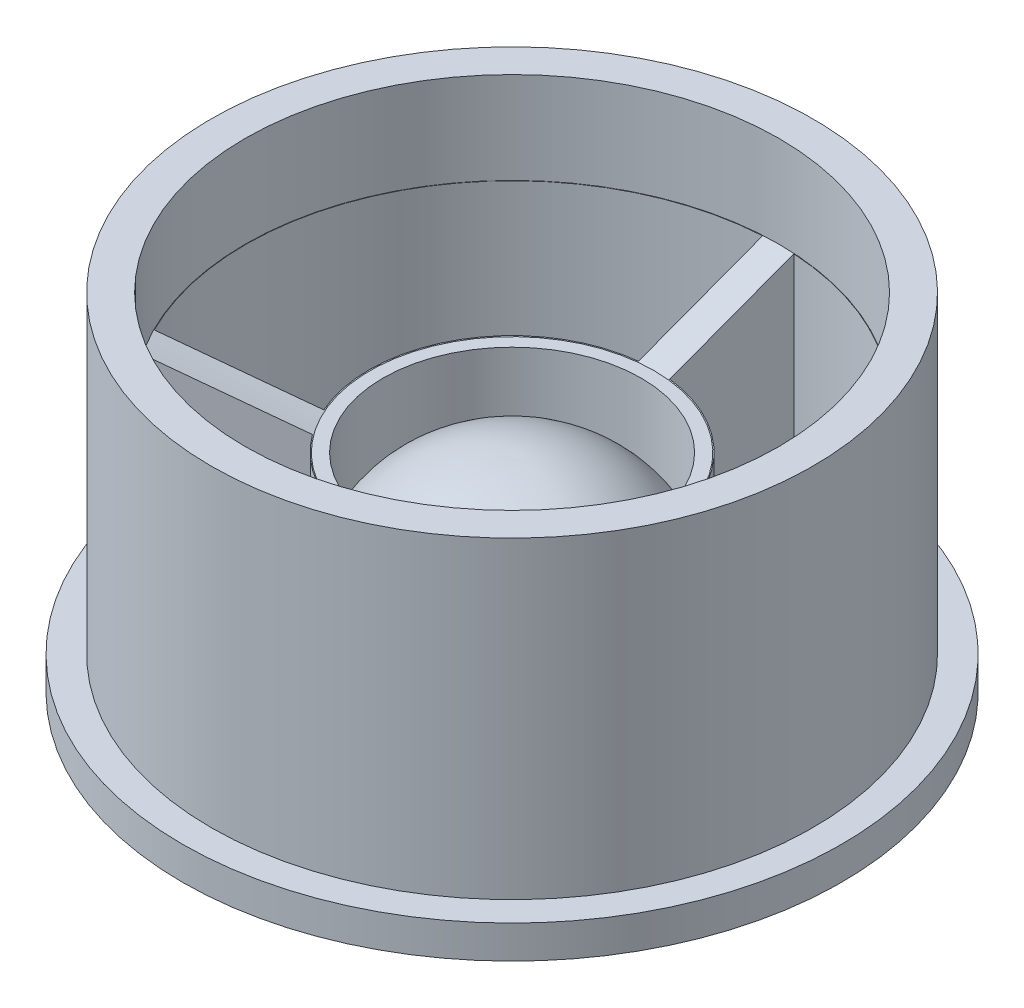
from build123d import *

# Parameters (mm, degrees)
SKETCH_1_R          = 10
SKETCH_1_R_2        = 9.128348481
EXTRUDE_2_DEPTH     = 1
SKETCH_1_4_R        = 9.128348481
EXTRUDE_4_DEPTH     = 10.5
SKETCH_1_5_R        = 1.1
CUT_EXTRUDE_1_DEPTH = 5


with BuildPart() as part:
    # 草图1 → 凸台-拉伸2 (new body)
    with BuildSketch(Plane(origin=(0, 0, 0), x_dir=(1, 0, 0), z_dir=(0, 1, 0))):
        Circle(SKETCH_1_R)
        Circle(SKETCH_1_R_2, mode=Mode.SUBTRACT)
    extrude(amount=EXTRUDE_2_DEPTH)

    # 草图1<4> → 凸台-拉伸4 (add)
    with BuildSketch(Plane(origin=(0, 0, 0), x_dir=(1, 0, 0), z_dir=(0, 1, 0))):
        Circle(SKETCH_1_4_R)
        with BuildLine():
            Line((0.473140602, 4.307795347), (0.473140602, 8.075783591))
            ThreePointArc((0.473140602, 8.075783591), (7.005826645, 4.044815899), (7.230404046, -3.628140015))
            Line((7.230404046, -3.628140015), (3.967230505, -1.744145892))
            ThreePointArc((3.967230505, -1.744145892), (3.753095001, 2.166850409), (0.473140602, 4.307795347))
        make_face(mode=Mode.SUBTRACT)
        with BuildLine():
            Line((-0.473140602, 8.075783591), (-0.473140602, 4.307795347))
            ThreePointArc((-0.473140602, 4.307795347), (-3.753095001, 2.166850409), (-3.967230505, -1.744145892))
            Line((-3.967230505, -1.744145892), (-7.230404046, -3.628140015))
            ThreePointArc((-7.230404046, -3.628140015), (-7.005826645, 4.044815899), (-0.473140602, 8.075783591))
        make_face(mode=Mode.SUBTRACT)
        with BuildLine():
            ThreePointArc((-3.494089903, -2.563649454), (0, -4.333700818), (3.494089903, -2.563649454))
            Line((3.494089903, -2.563649454), (6.757263444, -4.447643576))
            ThreePointArc((6.757263444, -4.447643576), (0, -8.089631799), (-6.757263444, -4.447643576))
            Line((-6.757263444, -4.447643576), (-3.494089903, -2.563649454))
        make_face(mode=Mode.SUBTRACT)
    extrude(amount=EXTRUDE_4_DEPTH)

    # 草图2 → 切除-旋转1 (revolve, cut)
    with BuildSketch(Plane(origin=(0, 0, 0), x_dir=(0, 0, -1), z_dir=(1, 0, 0))):
        with BuildLine():
            Line((8.099016848, 10.5), (8.099016848, 7.718955254))
            Line((8.099016848, 7.718955254), (4.307795347, 6.293437734))
            Line((4.307795347, 6.293437734), (3.916728598, 6.293437734))
            Line((3.916728598, 6.293437734), (3.916728598, 3.964130755))
            add(Edge.make_bspline(
                [(3.916728598, 3.964130755), (3.198487501, 5.366870317), (1.55626671, 6.233016223), (0, 6.17174819)],
                knots=[0, 0, 0, 0, 1, 1, 1, 1], degree=3))
            Line((0, 6.17174819), (0, 6.293437734))
            Line((0, 6.293437734), (0, 10.5))
            Line((0, 10.5), (8.099016848, 10.5))
        make_face()
    revolve(axis=Axis((0, 2.702728724, 0), (0, 1, 0)), mode=Mode.SUBTRACT)

    # 草图1<5> → 切除-拉伸1 (cut)
    with BuildSketch(Plane(origin=(0, 0, 0), x_dir=(1, 0, 0), z_dir=(0, 1, 0))):
        Circle(SKETCH_1_5_R)
    extrude(amount=CUT_EXTRUDE_1_DEPTH, mode=Mode.SUBTRACT)

    # 草图3 → 旋转1 (revolve)
    with BuildSketch(Plane(origin=(0, 0, 0), x_dir=(0, 0, -1), z_dir=(1, 0, 0))):
        with BuildLine():
            Line((1.1, 0), (1.1, -4))
            Line((1.1, -4), (1.858610419, -4))
            add(Edge.make_bspline(
                [(1.858610419, -4), (1.970625951, -1.457794417), (4.274857556, 0)],
                knots=[0, 0, 0, 1, 1, 1], degree=2))
            Line((4.274857556, 0), (1.1, 0))
        make_face()
    revolve(axis=Axis((0, -4.725, 0), (0, 1, 0)))


solid = part.part
